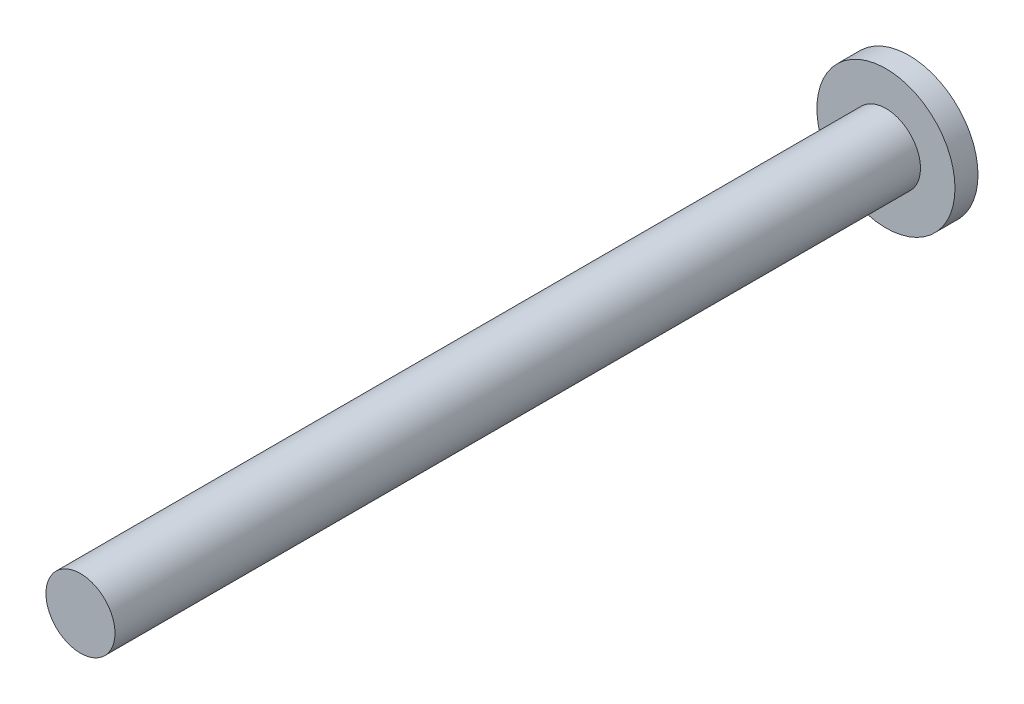
from build123d import *

# Parameters (mm, degrees)
ESQUISSE1_R        = 1.5
BOSS_EXTRU_1_DEPTH = 35
ESQUISSE1_3_R      = 3
BOSS_EXTRU_2_DEPTH = 1


with BuildPart() as part:
    # Esquisse1 → Boss.-Extru.1 (new body)
    with BuildSketch(Plane.XY):
        Circle(ESQUISSE1_R)
    extrude(amount=BOSS_EXTRU_1_DEPTH)

    # Esquisse1_3 → Boss.-Extru.2 (add)
    with BuildSketch(Plane.XY):
        Circle(ESQUISSE1_3_R)
    extrude(amount=-BOSS_EXTRU_2_DEPTH)


solid = part.part
